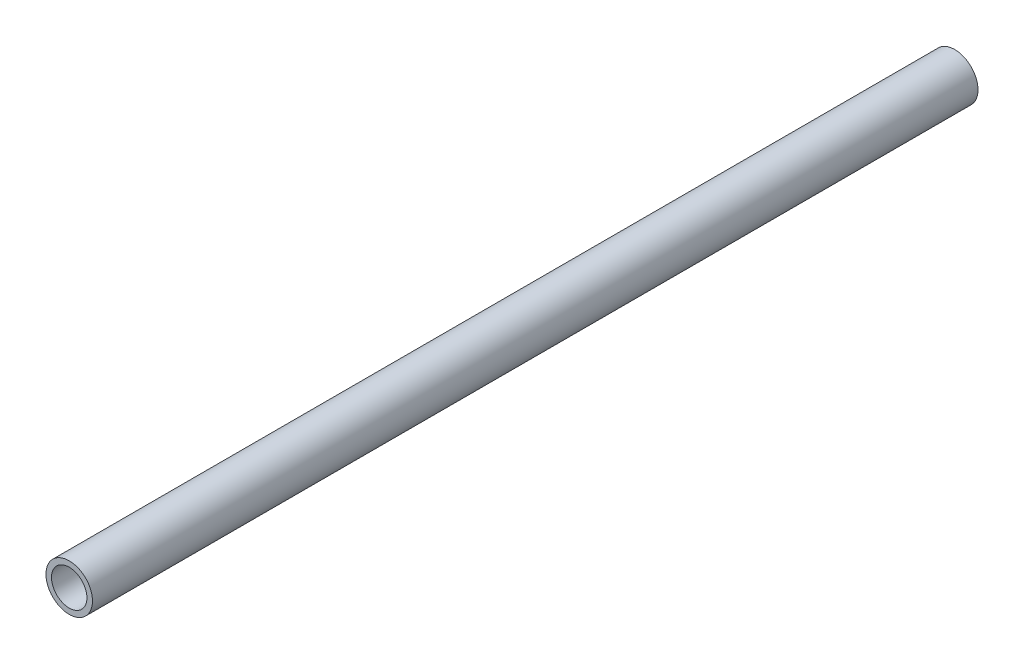
from build123d import *

# Parameters (mm, degrees)
SKETCH1_R           = 5.25
SKETCH1_R_2         = 4
BOSS_EXTRUDE1_DEPTH = 200


with BuildPart() as part:
    # Sketch1 → Boss-Extrude1 (new body)
    with BuildSketch(Plane.XY):
        Circle(SKETCH1_R)
        Circle(SKETCH1_R_2, mode=Mode.SUBTRACT)
    extrude(amount=-BOSS_EXTRUDE1_DEPTH)


solid = part.part
